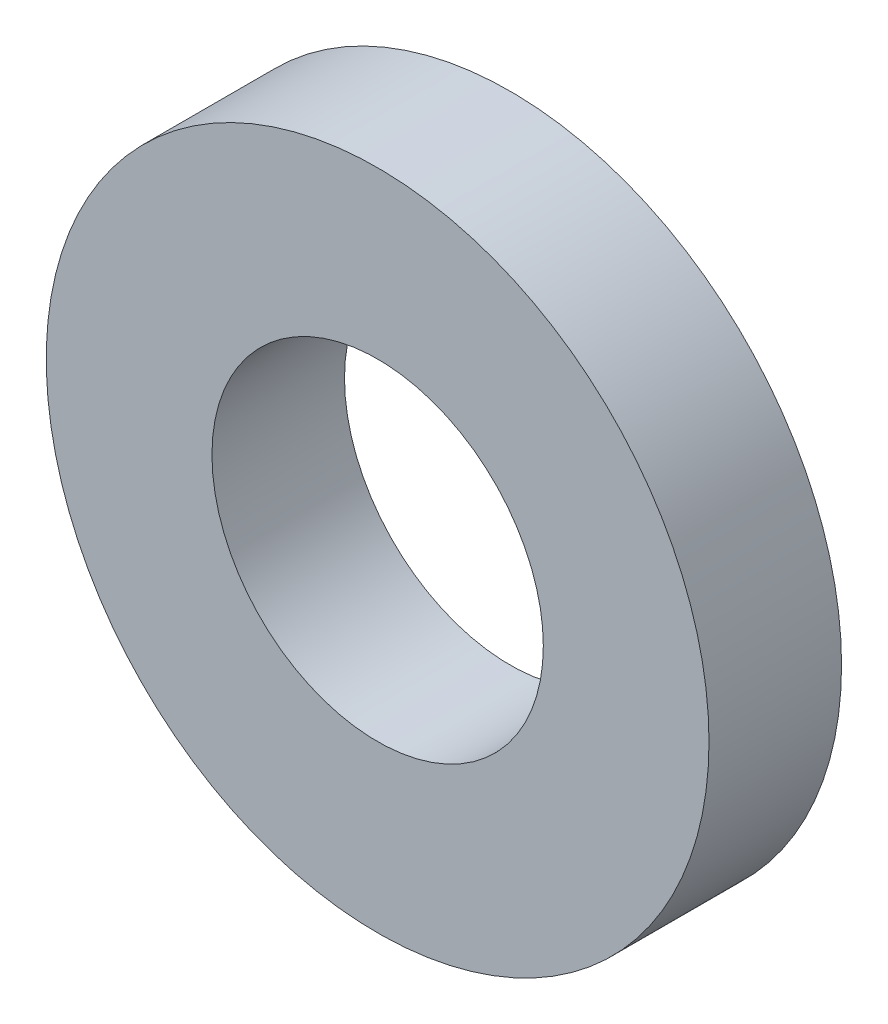
from build123d import *

# Parameters (mm, degrees)
SKETCH1_R           = 6.35
SKETCH1_R_2         = 3.175
BOSS_EXTRUDE1_DEPTH = 2.54


with BuildPart() as part:
    # Sketch1 → Boss-Extrude1 (new body)
    with BuildSketch(Plane.XY):
        Circle(SKETCH1_R)
        Circle(SKETCH1_R_2, mode=Mode.SUBTRACT)
    extrude(amount=BOSS_EXTRUDE1_DEPTH)


solid = part.part
